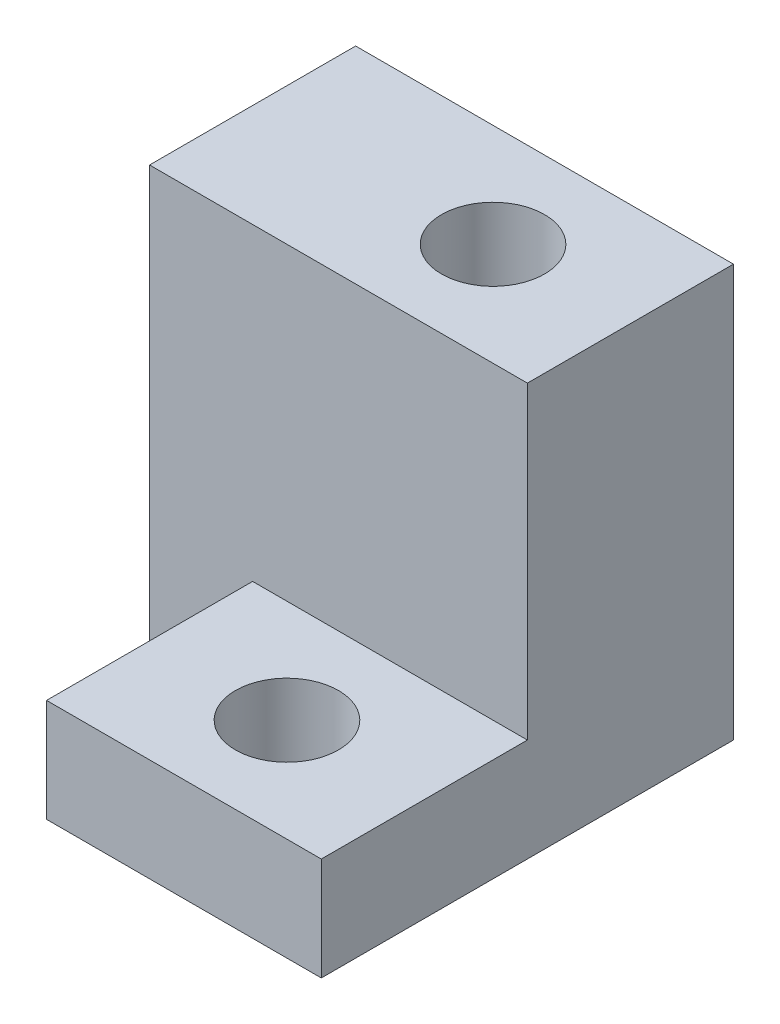
from build123d import *

# Parameters (mm, degrees)
SKETCH1_W           = 11
SKETCH1_H           = 12
BOSS_EXTRUDE1_DEPTH = 6
SKETCH2_W           = 8
SKETCH2_H           = 3
BOSS_EXTRUDE2_DEPTH = 6
SKETCH3_R           = 1.5
CUT_EXTRUDE1_DEPTH  = 6
SKETCH4_R           = 1.5
CUT_EXTRUDE2_DEPTH  = 16


with BuildPart() as part:
    # Sketch1 → Boss-Extrude1 (new body)
    with BuildSketch(Plane.XY):
        with Locations((5.5, 6)):
            Rectangle(SKETCH1_W, SKETCH1_H)
    extrude(amount=BOSS_EXTRUDE1_DEPTH)

    # Sketch2 → Boss-Extrude2 (add)
    with BuildSketch(Plane.XY.offset(6)):
        with Locations((7, 1.5)):
            Rectangle(SKETCH2_W, SKETCH2_H)
    extrude(amount=BOSS_EXTRUDE2_DEPTH)

    # Sketch3 → Cut-Extrude1 (cut)
    with BuildSketch(Plane(origin=(0, 3, 0), x_dir=(1, 0, 0), z_dir=(0, 1, 0))):
        with Locations((7, -9)):
            Circle(SKETCH3_R)
    extrude(amount=-CUT_EXTRUDE1_DEPTH, mode=Mode.SUBTRACT)

    # Sketch4 → Cut-Extrude2 (cut)
    with BuildSketch(Plane(origin=(0, 12, 0), x_dir=(1, 0, 0), z_dir=(0, 1, 0))):
        with Locations((7, -3)):
            Circle(SKETCH4_R)
    extrude(amount=-CUT_EXTRUDE2_DEPTH, mode=Mode.SUBTRACT)


solid = part.part
